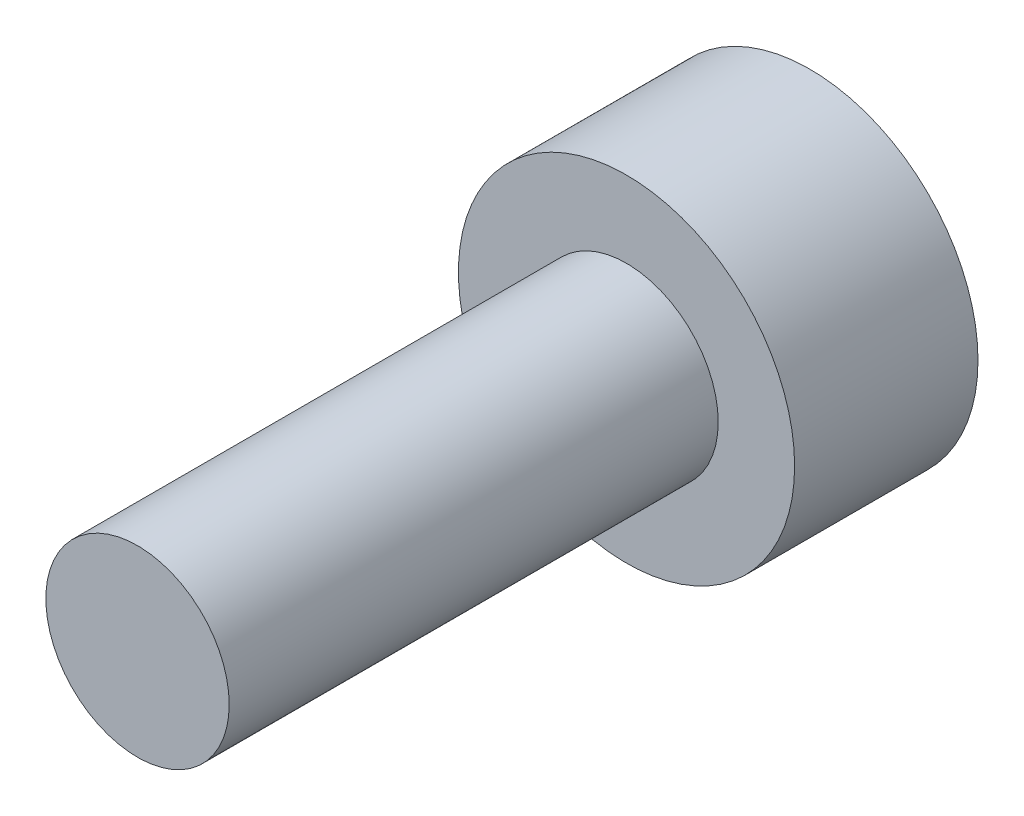
from build123d import *

# Parameters (mm, degrees)
SKETCH_1_R          = 2.75
EXTRUDE_1_DEPTH     = 3
CUT_EXTRUDE_1_DEPTH = 1.3
SKETCH_3_R          = 1.5
EXTRUDE_2_DEPTH     = 8


with BuildPart() as part:
    # 草图1 → 凸台-拉伸1 (new body)
    with BuildSketch(Plane.XY):
        Circle(SKETCH_1_R)
    extrude(amount=EXTRUDE_1_DEPTH)

    # 草图2 → 切除-拉伸1 (cut)
    with BuildSketch(Plane(origin=(0, 0, 0), x_dir=(-1, 0, 0), z_dir=(0, 0, -1))):
        Polygon((-1.25, 0.721687836), (-1.25, -0.721687836), (0, -1.443375673), (1.25, -0.721687836), (1.25, 0.721687836), (0, 1.443375673), align=None)
    extrude(amount=-CUT_EXTRUDE_1_DEPTH, mode=Mode.SUBTRACT)

    # 草图3 → 凸台-拉伸2 (add)
    with BuildSketch(Plane.XY.offset(3)):
        Circle(SKETCH_3_R)
    extrude(amount=EXTRUDE_2_DEPTH)


solid = part.part
